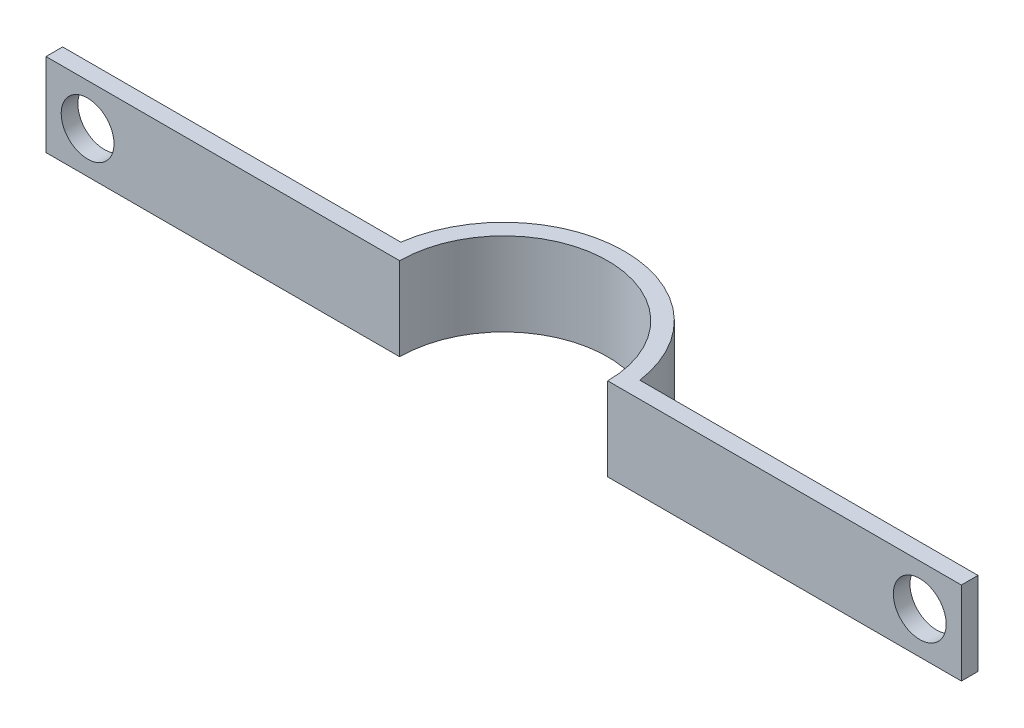
from build123d import *

# Parameters (mm, degrees)
BOSS_EXTRUDE1_DEPTH            = 10
HOLE1_D                        = 6.35
HOLE1_DEPTH                    = 2
F_25_0_25_DIAMETER_HOLE1_D     = 25
F_25_0_25_DIAMETER_HOLE1_DEPTH = 10
SCALE1_SCALE                   = 4


with BuildPart() as part:
    # Sketch1 → Boss-Extrude1 (new body)
    with BuildSketch(Plane.XZ.offset(10)):
        with BuildLine():
            Line((55, 0), (-55, 0))
            Line((-55, 0), (-55, -2))
            Line((-55, -2), (-14.361406616, -2))
            ThreePointArc((-14.361406616, -2), (0, -14.5), (14.361406616, -2))
            Line((14.361406616, -2), (55, -2))
            Line((55, -2), (55, 0))
        make_face()
    extrude(amount=-BOSS_EXTRUDE1_DEPTH)

    # Hole1
    with Locations(Plane(origin=(0, 0, -2), x_dir=(-1, 0, 0), z_dir=(0, 0, -1))):
        with Locations((-50, -5), (50, -5)):
            Hole(HOLE1_D / 2, depth=HOLE1_DEPTH)

    # Ø25.0 (25) Diameter Hole1
    with Locations(Plane(origin=(0, -10, 0), x_dir=(-1, 0, 0), z_dir=(0, -1, 0))):
        with Locations((0, 0)):
            Hole(F_25_0_25_DIAMETER_HOLE1_D / 2, depth=F_25_0_25_DIAMETER_HOLE1_DEPTH)


with BuildPart() as part_1:
    # Scale1: scaled about (0, -5, -3.754985593)
    add(part.part.scale(SCALE1_SCALE).moved(Location((0, 15, 11.264956779))))


solid = part_1.part
